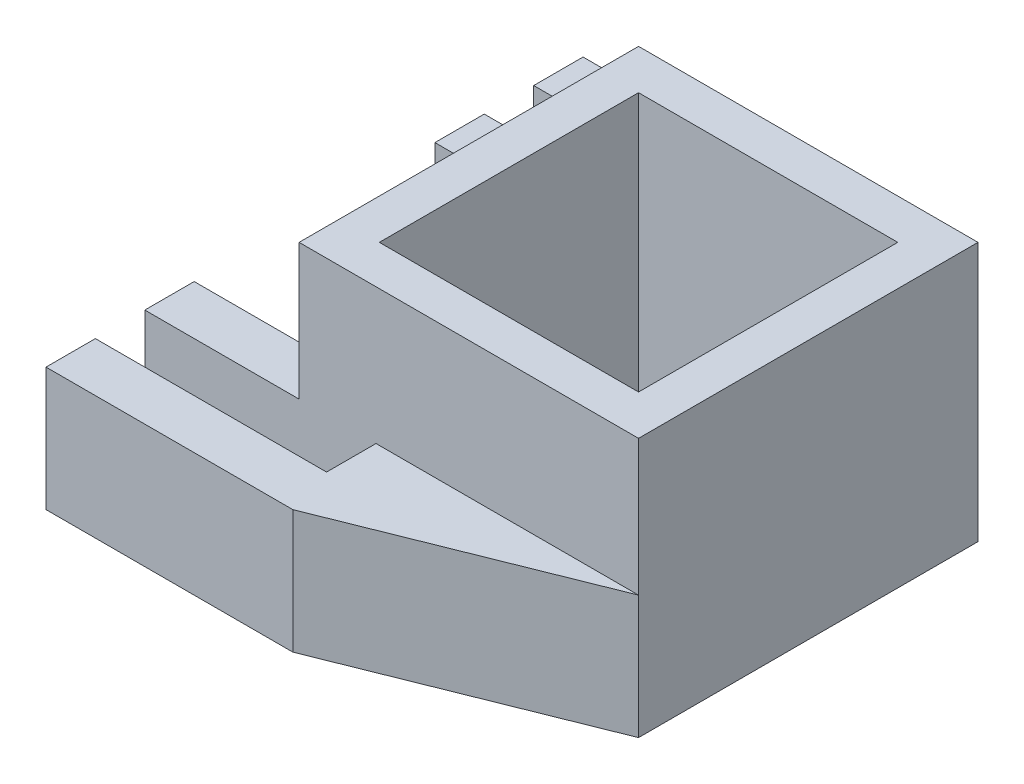
from build123d import *

# Parameters (mm, degrees)
SKETCH1_W           = 55
SKETCH1_H           = 55
SKETCH1_W_2         = 42
SKETCH1_H_2         = 42
BOSS_EXTRUDE1_DEPTH = 42
SKETCH2_W           = 25
SKETCH2_H           = 8
BOSS_EXTRUDE2_DEPTH = 20


with BuildPart() as part:
    # Sketch1 → Boss-Extrude1 (new body)
    with BuildSketch(Plane(origin=(0, 0, 0), x_dir=(1, 0, 0), z_dir=(0, 1, 0))):
        with Locations((21, 21)):
            Rectangle(SKETCH1_W, SKETCH1_H)
        with Locations((21, 21)):
            Rectangle(SKETCH1_W_2, SKETCH1_H_2, mode=Mode.SUBTRACT)
    extrude(amount=BOSS_EXTRUDE1_DEPTH)

    # Sketch2 → Boss-Extrude2 (add)
    with BuildSketch(Plane.XZ):
        Polygon((5.96, 6.5), (5.96, 14.51), (-31.5, 14.51), (-31.5, 22.51), (8.5, 22.51), (48.5, 6.5), align=None)
        Polygon((48.5, -48.5), (5.96, -48.5), (5.96, -56.51), (-31.5, -56.51), (-31.5, -64.51), (8.5, -64.51), align=None)
        with Locations((-19, -44.5)):
            Rectangle(SKETCH2_W, SKETCH2_H)
        with Locations((-19, 2.5)):
            Rectangle(SKETCH2_W, SKETCH2_H)
    extrude(amount=-BOSS_EXTRUDE2_DEPTH)


solid = part.part
